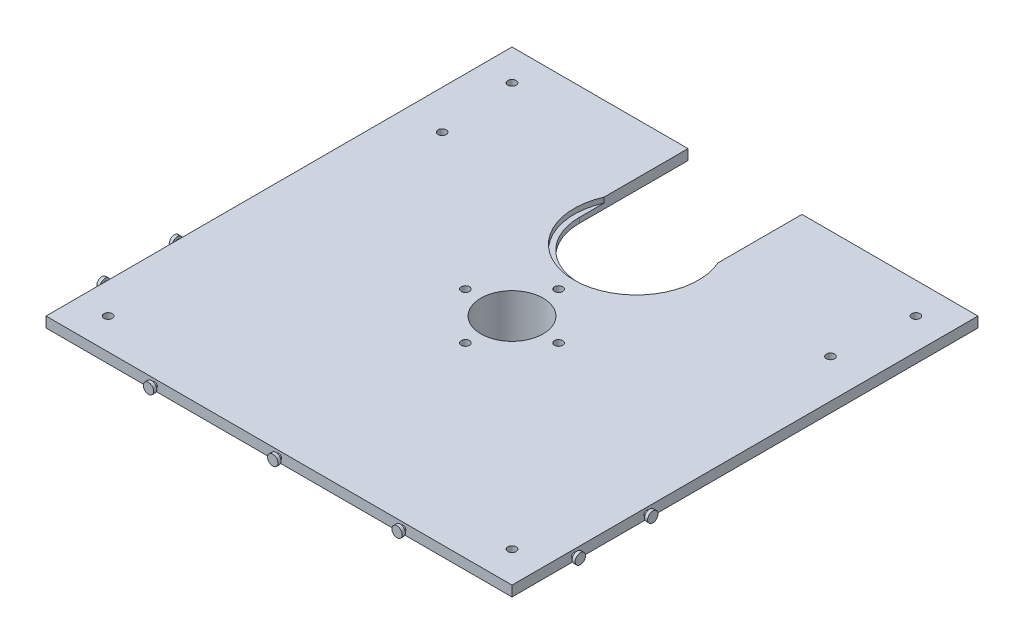
from build123d import *

# Parameters (mm, degrees)
CROQUIS1_W              = 450
CROQUIS1_H              = 450
CROQUIS1_R              = 30
CROQUIS1_R_2            = 55
SALIENTE_EXTRUIR1_DEPTH = 10
CROQUIS7_R              = 4
CORTAR_EXTRUIR6_DEPTH   = 11
CROQUIS8_R              = 60
CROQUIS8_R_2            = 55
CORTAR_EXTRUIR7_DEPTH   = 5
CROQUIS9_R              = 55
CORTAR_EXTRUIR8_DEPTH   = 11
CROQUIS10_R             = 35
CROQUIS10_R_2           = 30
SALIENTE_EXTRUIR2_DEPTH = 100
CROQUIS11_R             = 2.5
SALIENTE_EXTRUIR3_DEPTH = 3
CROQUIS12_R             = 5
SALIENTE_EXTRUIR4_DEPTH = 3
CROQUIS14_R             = 2.5
SALIENTE_EXTRUIR5_DEPTH = 3
CROQUIS15_R             = 5
SALIENTE_EXTRUIR6_DEPTH = 3


with BuildPart() as part:
    # Croquis1 → Saliente-Extruir1 (new body)
    with BuildSketch(Plane(origin=(0, 0, 0), x_dir=(1, 0, 0), z_dir=(0, 1, 0))):
        Rectangle(CROQUIS1_W, CROQUIS1_H)
        Circle(CROQUIS1_R, mode=Mode.SUBTRACT)
        with Locations((0, 120)):
            Circle(CROQUIS1_R_2, mode=Mode.SUBTRACT)
    extrude(amount=SALIENTE_EXTRUIR1_DEPTH)

    # Croquis7 → Cortar-Extruir6 (cut, through all)
    with BuildSketch(Plane(origin=(0, 10, 0), x_dir=(1, 0, 0), z_dir=(0, 1, 0))):
        with Locations((-195, 195)):
            Circle(CROQUIS7_R)
        with Locations((195, 195)):
            Circle(CROQUIS7_R)
        with Locations((195, -195)):
            Circle(CROQUIS7_R)
        with Locations((-195, -195)):
            Circle(CROQUIS7_R)
        with Locations((-45, 0)):
            Circle(CROQUIS7_R)
        with Locations((0, 45)):
            Circle(CROQUIS7_R)
        with Locations((0, -45)):
            Circle(CROQUIS7_R)
        with Locations((45, 0)):
            Circle(CROQUIS7_R)
        with Locations((-187.5, 120)):
            Circle(CROQUIS7_R)
        with Locations((187.5, 120)):
            Circle(CROQUIS7_R)
    extrude(amount=-CORTAR_EXTRUIR6_DEPTH, mode=Mode.SUBTRACT)

    # Croquis8 → Cortar-Extruir7 (cut)
    with BuildSketch(Plane(origin=(0, 10, 0), x_dir=(1, 0, 0), z_dir=(0, 1, 0))):
        with Locations((0, 120)):
            Circle(CROQUIS8_R)
        with Locations((0, 120)):
            Circle(CROQUIS8_R_2, mode=Mode.SUBTRACT)
    extrude(amount=-CORTAR_EXTRUIR7_DEPTH, mode=Mode.SUBTRACT)

    # Croquis9 → Cortar-Extruir8 (cut, through all)
    with BuildSketch(Plane(origin=(0, 10, 0), x_dir=(1, 0, 0), z_dir=(0, 1, 0))):
        with Locations((0, 120)):
            Circle(CROQUIS9_R)
        Polygon((0, 120), (55, 120), (55, 225), (-55, 225), (-55, 120), align=None)
    extrude(amount=-CORTAR_EXTRUIR8_DEPTH, mode=Mode.SUBTRACT)

    # Croquis10 → Saliente-Extruir2 (add)
    with BuildSketch(Plane.XZ):
        Circle(CROQUIS10_R)
        Circle(CROQUIS10_R_2, mode=Mode.SUBTRACT)
    extrude(amount=SALIENTE_EXTRUIR2_DEPTH)

    # Croquis11 → Saliente-Extruir3 (add)
    with BuildSketch(Plane(origin=(225, 0, 0), x_dir=(0, 0, -1), z_dir=(1, 0, 0))):
        with Locations((-165, 5)):
            Circle(CROQUIS11_R)
        with Locations((-95, 5)):
            Circle(CROQUIS11_R)
    saliente_extruir3 = extrude(amount=SALIENTE_EXTRUIR3_DEPTH)

    # Croquis12 → Saliente-Extruir4 (add)
    with BuildSketch(Plane(origin=(228, 0, 0), x_dir=(0, 0, -1), z_dir=(1, 0, 0))):
        with Locations((-165, 5)):
            Circle(CROQUIS12_R)
        with Locations((-95, 5)):
            Circle(CROQUIS12_R)
    saliente_extruir4 = extrude(amount=SALIENTE_EXTRUIR4_DEPTH)

    # Simetría1: Saliente-Extruir3, Saliente-Extruir4 across plane
    add(saliente_extruir3.mirror(Plane(origin=(0, 0, 0), x_dir=(0, 0, 1), z_dir=(1, 0, 0))))
    add(saliente_extruir4.mirror(Plane(origin=(0, 0, 0), x_dir=(0, 0, 1), z_dir=(1, 0, 0))))

    # Croquis14 → Saliente-Extruir5 (add)
    with BuildSketch(Plane.XY.offset(225)):
        with Locations((-120, 5)):
            Circle(CROQUIS14_R)
        with Locations((0, 5)):
            Circle(CROQUIS14_R)
        with Locations((120, 5)):
            Circle(CROQUIS14_R)
    extrude(amount=SALIENTE_EXTRUIR5_DEPTH)

    # Croquis15 → Saliente-Extruir6 (add)
    with BuildSketch(Plane.XY.offset(228)):
        with Locations((-120, 5)):
            Circle(CROQUIS15_R)
        with Locations((0, 5)):
            Circle(CROQUIS15_R)
        with Locations((120, 5)):
            Circle(CROQUIS15_R)
    extrude(amount=SALIENTE_EXTRUIR6_DEPTH)


solid = part.part
